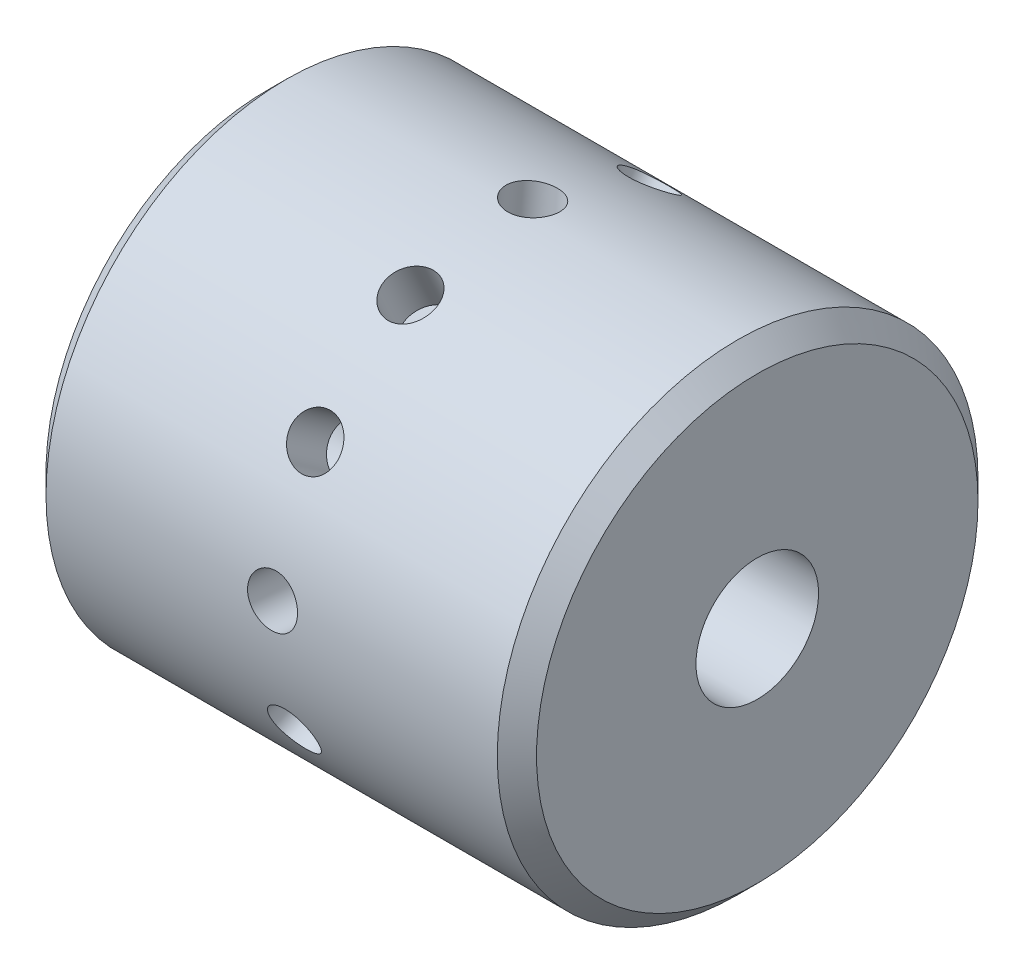
from build123d import *

# Parameters (mm, degrees)
SKETCH1_R           = 12.446
BOSS_EXTRUDE1_DEPTH = 12.7
CHAMFER1_SIZE       = 1.016
CHAMFER2_SIZE       = 1.016
SKETCH2_R           = 3.175
CUT_EXTRUDE1_DEPTH  = 25.4
CIRPATTERN4_COUNT   = 12


with BuildPart() as part:
    # Sketch1 → Boss-Extrude1 (new body, symmetric)
    with BuildSketch(Plane(origin=(0, 0, 0), x_dir=(0, 0, -1), z_dir=(1, 0, 0))):
        Circle(SKETCH1_R)
    extrude(amount=BOSS_EXTRUDE1_DEPTH, both=True)

    # Chamfer1
    chamfer1_edges = [part.edges().sort_by_distance(p)[0] for p in [
        (12.7, 0, 12.446),
    ]]
    chamfer(chamfer1_edges, length=CHAMFER1_SIZE)

    # Chamfer2
    chamfer2_edges = [part.edges().sort_by_distance(p)[0] for p in [
        (-12.7, 0, 12.446),
    ]]
    chamfer(chamfer2_edges, length=CHAMFER2_SIZE)

    # Sketch2 → Cut-Extrude1 (cut)
    with BuildSketch(Plane(origin=(12.7, 0, 0), x_dir=(0, 0, -1), z_dir=(1, 0, 0))):
        Circle(SKETCH2_R)
    extrude(amount=-CUT_EXTRUDE1_DEPTH, mode=Mode.SUBTRACT)

    # Sketch4 → #38 (0.1015) Diameter Hole1 (revolve, cut)
    with BuildSketch(Plane(origin=(0, 10.202452378, -7.128315472), x_dir=(0, 0.572739472, 0.819737456), z_dir=(1, 0, 0))):
        Polygon((0, 0), (0, 3.314539381), (1.28905, 2.54), (1.28905, 0), align=None)
    f_38_0_1015_diameter_hole1 = revolve(axis=Axis((0, 15.407785224, -10.765211121), (0, -0.819737456, 0.572739472)), mode=Mode.SUBTRACT)

    # CirPattern4: #38 (0.1015) Diameter Hole1 ×12 about axis
    cirpattern4_axis = Axis((12.7, 0, 0), (-1, 0, 0))
    for i in range(1, CIRPATTERN4_COUNT):
        add(f_38_0_1015_diameter_hole1.rotate(cirpattern4_axis, i * 360 / CIRPATTERN4_COUNT), mode=Mode.SUBTRACT)


solid = part.part
